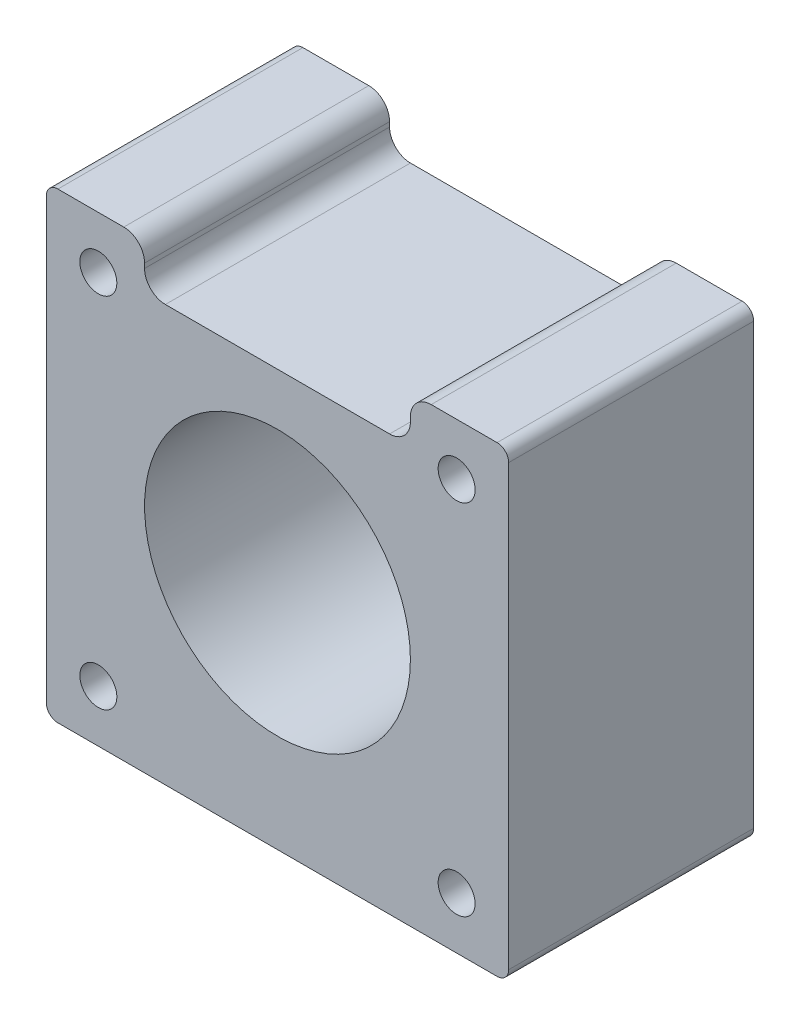
from build123d import *

# Parameters (mm, degrees)
SKETCH1_R           = 11.5
SKETCH1_R_2         = 1.6
BOSS_EXTRUDE1_DEPTH = 21.2


with BuildPart() as part:
    # Sketch1 → Boss-Extrude1 (new body)
    with BuildSketch(Plane.XY):
        with BuildLine():
            Line((-20, 19), (-20, -19))
            ThreePointArc((-20, -19), (-19.707106781, -19.707106781), (-19, -20))
            Line((-19, -20), (19, -20))
            ThreePointArc((19, -20), (19.707106781, -19.707106781), (20, -19))
            Line((20, -19), (20, 19))
            ThreePointArc((20, 19), (19.707106781, 19.707106781), (19, 20))
            Line((19, 20), (13.3, 20))
            ThreePointArc((13.3, 20), (12.027207794, 19.472792206), (11.5, 18.2))
            Line((11.5, 18.2), (11.5, 17.8))
            ThreePointArc((11.5, 17.8), (10.972792206, 16.527207794), (9.7, 16))
            Line((9.7, 16), (-9.7, 16))
            ThreePointArc((-9.7, 16), (-10.972792206, 16.527207794), (-11.5, 17.8))
            Line((-11.5, 17.8), (-11.5, 18.2))
            ThreePointArc((-11.5, 18.2), (-12.027207794, 19.472792206), (-13.3, 20))
            Line((-13.3, 20), (-19, 20))
            ThreePointArc((-19, 20), (-19.707106781, 19.707106781), (-20, 19))
        make_face()
        Circle(SKETCH1_R, mode=Mode.SUBTRACT)
        with Locations((-15.5, 15.5)):
            Circle(SKETCH1_R_2, mode=Mode.SUBTRACT)
        with Locations((15.5, 15.5)):
            Circle(SKETCH1_R_2, mode=Mode.SUBTRACT)
        with Locations((15.5, -15.5)):
            Circle(SKETCH1_R_2, mode=Mode.SUBTRACT)
        with Locations((-15.5, -15.5)):
            Circle(SKETCH1_R_2, mode=Mode.SUBTRACT)
    extrude(amount=BOSS_EXTRUDE1_DEPTH)


solid = part.part
